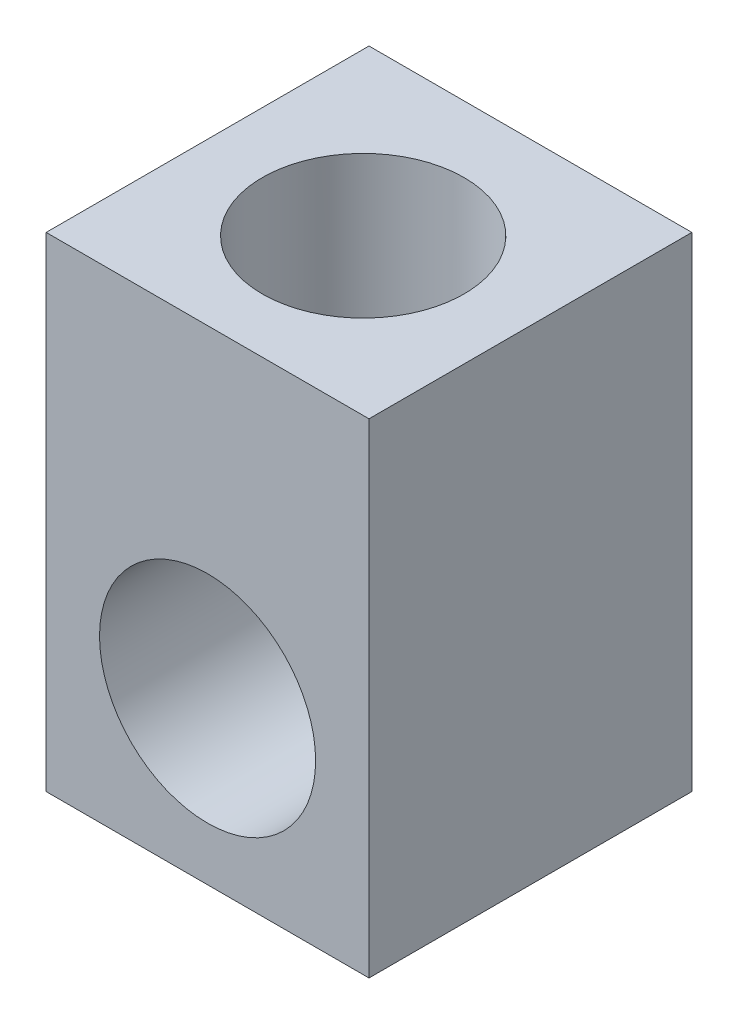
from build123d import *

# Parameters (mm, degrees)
SKETCH1_W               = 50.8
SKETCH1_H               = 50.8
BOSS_EXTRUDE1_DEPTH     = 76.2
CUT_EXTRUDE1_DEPTH      = 76.2
CUT_EXTRUDE2_REACH      = 106.727
CUT_EXTRUDE2_END_RADIUS = 17


with BuildPart() as part:
    # Sketch1 → Boss-Extrude1 (new body)
    with BuildSketch(Plane(origin=(0, 0, 0), x_dir=(1, 0, 0), z_dir=(0, 1, 0))):
        with Locations((25.4, 25.4)):
            Rectangle(SKETCH1_W, SKETCH1_H)
    extrude(amount=BOSS_EXTRUDE1_DEPTH)

    # Sketch2 → Cut-Extrude1 (cut)
    with BuildSketch(Plane(origin=(0, 0, -50.8), x_dir=(-1, 0, 0), z_dir=(0, 0, -1))):
        with BuildLine():
            ThreePointArc((-8.4, 25.4), (-37.42081528, 37.42081528), (-25.4, 8.4))
            Line((-25.4, 8.4), (-25.4, 25.4))
            Line((-25.4, 25.4), (-8.4, 25.4))
        make_face()
        with BuildLine():
            Line((-25.4, 25.4), (-25.4, 8.4))
            ThreePointArc((-25.4, 8.4), (-13.37918472, 13.37918472), (-8.4, 25.4))
            Line((-8.4, 25.4), (-25.4, 25.4))
        make_face()
    extrude(amount=-CUT_EXTRUDE1_DEPTH, mode=Mode.SUBTRACT)

    # Cut-Extrude2: up to this cylinder (the profile starts outside it)
    cut_extrude2_end = Plane(origin=(25.4, 25.4, -26.731477), z_dir=(0, 0, -1)) * Cylinder(CUT_EXTRUDE2_END_RADIUS, 257.437412, mode=Mode.PRIVATE)
    # Sketch3 → Cut-Extrude2 (cut, up to the surface)
    with BuildSketch(Plane(origin=(0, 76.2, 0), x_dir=(1, 0, 0), z_dir=(0, 1, 0)), mode=Mode.PRIVATE) as cut_extrude2_sk1:
        with BuildLine():
            ThreePointArc((41.275, 24.485623633), (36.625320151, 35.710943784), (25.4, 40.360623633))
            Line((25.4, 40.360623633), (25.4, 24.485623633))
            Line((25.4, 24.485623633), (9.525, 24.485623633))
            ThreePointArc((9.525, 24.485623633), (25.4, 8.610623633), (41.275, 24.485623633))
        make_face()
    cut_extrude2_tool1 = extrude(cut_extrude2_sk1.sketch, amount=-CUT_EXTRUDE2_REACH, mode=Mode.PRIVATE) - cut_extrude2_end
    add(cut_extrude2_tool1.solids().sort_by_distance((27.645853, 76.2, -22.239771))[0], mode=Mode.SUBTRACT)
    # Sketch3 → Cut-Extrude2 (cut, up to the surface)
    with BuildSketch(Plane(origin=(0, 76.2, 0), x_dir=(1, 0, 0), z_dir=(0, 1, 0)), mode=Mode.PRIVATE) as cut_extrude2_sk2:
        with BuildLine():
            Line((25.4, 24.485623633), (25.4, 40.360623633))
            ThreePointArc((25.4, 40.360623633), (14.174679849, 35.710943784), (9.525, 24.485623633))
            Line((9.525, 24.485623633), (25.4, 24.485623633))
        make_face()
    cut_extrude2_tool2 = extrude(cut_extrude2_sk2.sketch, amount=-CUT_EXTRUDE2_REACH, mode=Mode.PRIVATE) - cut_extrude2_end
    add(cut_extrude2_tool2.solids().sort_by_distance((18.662441, 76.2, -31.223183))[0], mode=Mode.SUBTRACT)
    # Sketch3 → Cut-Extrude2 (cut, up to the surface)
    with BuildSketch(Plane(origin=(0, 76.2, 0), x_dir=(1, 0, 0), z_dir=(0, 1, 0)), mode=Mode.PRIVATE) as cut_extrude2_sk3:
        with BuildLine():
            ThreePointArc((41.275, 24.485623633), (36.625320151, 35.710943784), (25.4, 40.360623633))
            Line((25.4, 40.360623633), (25.4, 24.485623633))
            Line((25.4, 24.485623633), (9.525, 24.485623633))
            ThreePointArc((9.525, 24.485623633), (25.4, 8.610623633), (41.275, 24.485623633))
        make_face()
    cut_extrude2_tool3 = extrude(cut_extrude2_sk3.sketch, amount=-CUT_EXTRUDE2_REACH, mode=Mode.PRIVATE) - cut_extrude2_end
    add(cut_extrude2_tool3.solids().sort_by_distance((27.645853, 76.2, -22.239771))[0], mode=Mode.SUBTRACT)
    # Sketch3 → Cut-Extrude2 (cut, up to the surface)
    with BuildSketch(Plane(origin=(0, 76.2, 0), x_dir=(1, 0, 0), z_dir=(0, 1, 0)), mode=Mode.PRIVATE) as cut_extrude2_sk4:
        with BuildLine():
            Line((25.4, 24.485623633), (25.4, 40.360623633))
            ThreePointArc((25.4, 40.360623633), (14.174679849, 35.710943784), (9.525, 24.485623633))
            Line((9.525, 24.485623633), (25.4, 24.485623633))
        make_face()
    cut_extrude2_tool4 = extrude(cut_extrude2_sk4.sketch, amount=-CUT_EXTRUDE2_REACH, mode=Mode.PRIVATE) - cut_extrude2_end
    add(cut_extrude2_tool4.solids().sort_by_distance((18.662441, 76.2, -31.223183))[0], mode=Mode.SUBTRACT)


solid = part.part
